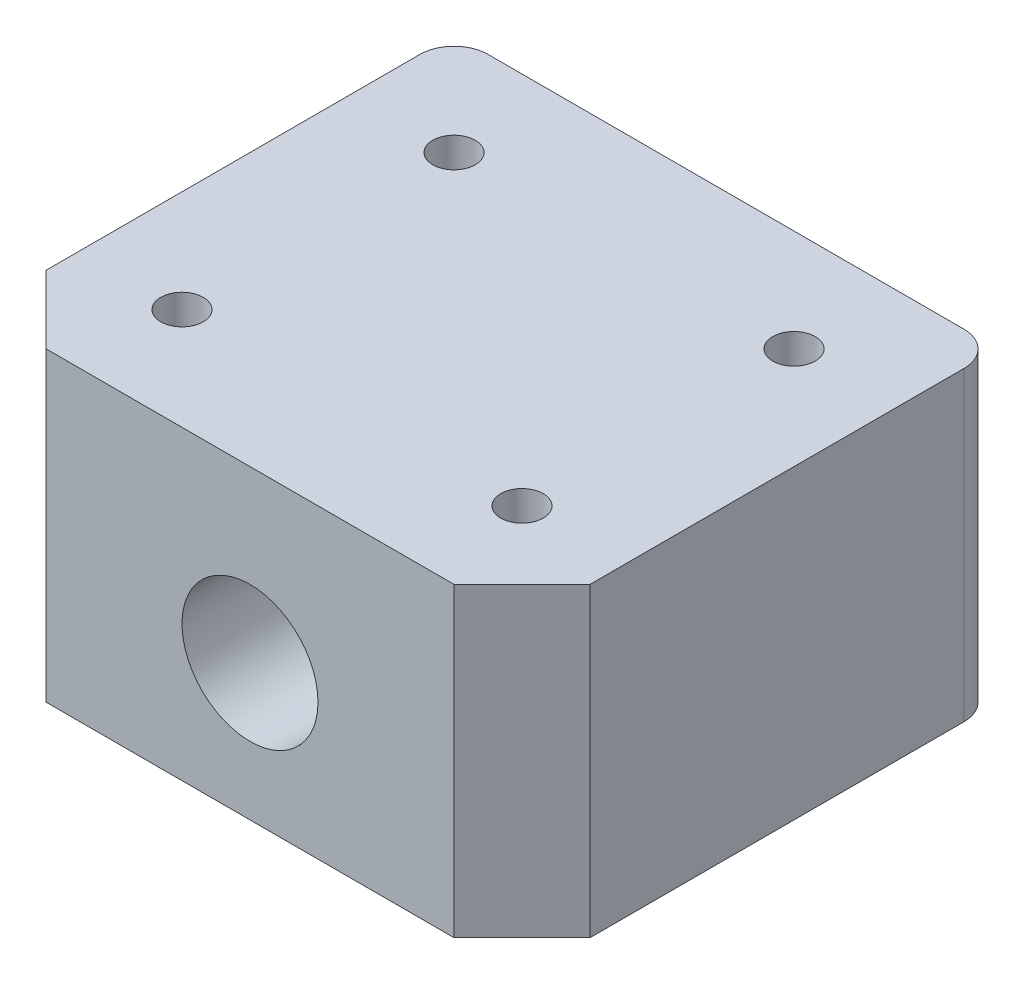
from build123d import *

# Parameters (mm, degrees)
ESQUISSE1_W         = 16
ESQUISSE1_H         = 9
ESQUISSE1_R         = 2
BOSS_EXTRU_1_DEPTH  = 7
TROU_TARAUD_M1_61_D = 1.25
CHANFREIN1_SIZE     = 2
CONG_1_R            = 1


with BuildPart() as part:
    # Esquisse1 → Boss.-Extru.1 (new body)
    with BuildSketch(Plane.XY):
        with Locations((0, 0.5)):
            Rectangle(ESQUISSE1_W, ESQUISSE1_H)
        Circle(ESQUISSE1_R, mode=Mode.SUBTRACT)
    boss_extru_1 = extrude(amount=BOSS_EXTRU_1_DEPTH)

    # Trou taraudé M1.61 (through all)
    with Locations(Plane(origin=(-5, 5, 4), x_dir=(0, 0, 1), z_dir=(0, 1, 0))):
        with Locations((0, 0), (0, 10)):
            trou_taraud_m1_61 = Hole(TROU_TARAUD_M1_61_D / 2)

    # Symétrie1: Boss.-Extru.1, Trou taraudé M1.61 across plane
    add(boss_extru_1.mirror(Plane(origin=(-8, -4, 0), x_dir=(1, 0, 0), z_dir=(0, 0, 1))))
    add(trou_taraud_m1_61.mirror(Plane(origin=(-8, -4, 0), x_dir=(1, 0, 0), z_dir=(0, 0, 1))), mode=Mode.SUBTRACT)

    # Chanfrein1
    chanfrein1_edges = [part.edges().sort_by_distance(p)[0] for p in [
        (8, 0.5, 7),
        (-8, 0.5, 7),
    ]]
    chamfer(chanfrein1_edges, length=CHANFREIN1_SIZE)

    # Congé1
    cong_1_edges = [part.edges().sort_by_distance(p)[0] for p in [
        (-8, 0.5, -7),
        (8, 0.5, -7),
    ]]
    fillet(cong_1_edges, radius=CONG_1_R)


solid = part.part
